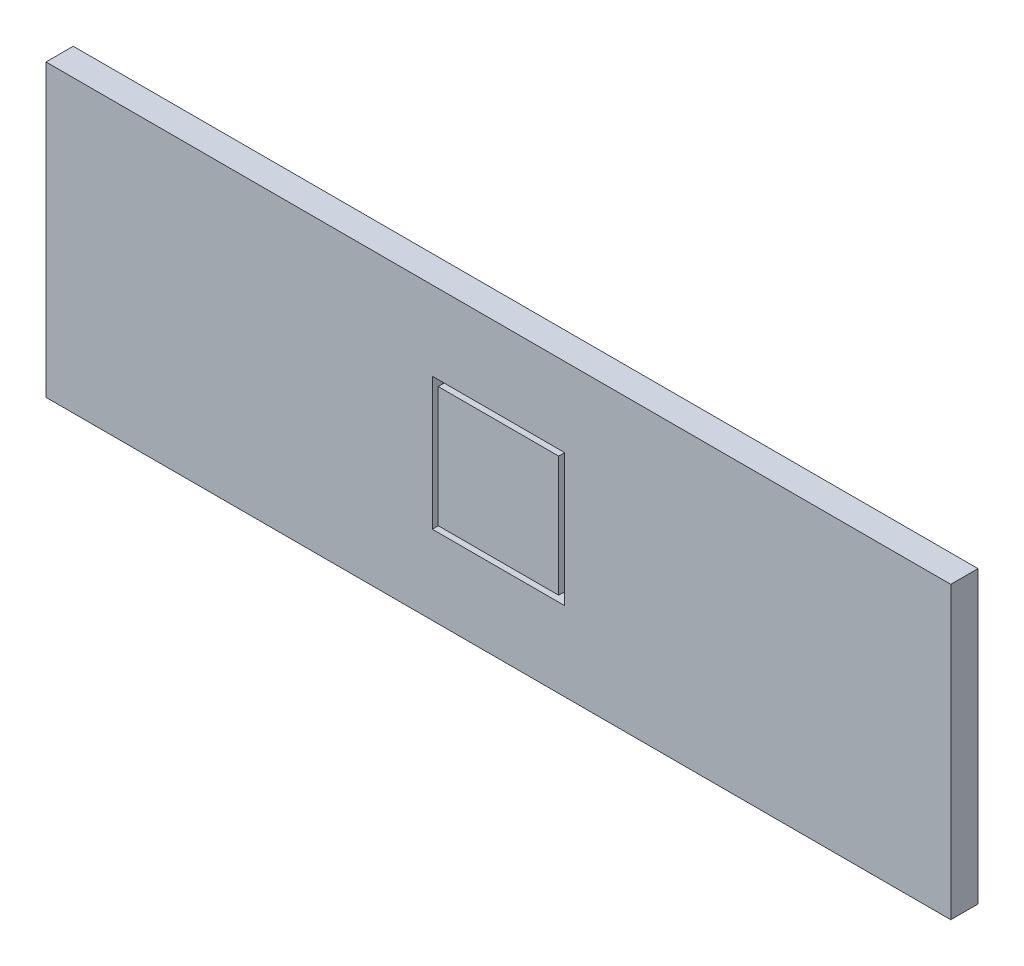
from build123d import *

# Parameters (mm, degrees)
SKETCH1_W           = 598
SKETCH1_H           = 192
BOSS_EXTRUDE1_DEPTH = 18
SKETCH2_W           = 87.4
SKETCH2_H           = 87.6
SKETCH2_W_2         = 79.646425984
SKETCH2_H_2         = 79.646425984
CUT_EXTRUDE1_DEPTH  = 7
CUT_EXTRUDE2_DEPTH  = 10.5


with BuildPart() as part:
    # Sketch1 → Boss-Extrude1 (new body)
    with BuildSketch(Plane.XY):
        Rectangle(SKETCH1_W, SKETCH1_H)
    extrude(amount=BOSS_EXTRUDE1_DEPTH)

    # Sketch2 → Cut-Extrude1 (cut)
    with BuildSketch(Plane.XY.offset(18)):
        Rectangle(SKETCH2_W, SKETCH2_H)
        Rectangle(SKETCH2_W_2, SKETCH2_H_2, mode=Mode.SUBTRACT)
    extrude(amount=-CUT_EXTRUDE1_DEPTH, mode=Mode.SUBTRACT)

    # Sketch3 → Cut-Extrude2 (cut)
    with BuildSketch(Plane.XY.offset(11)):
        with BuildLine():
            Line((30, -33.2), (-30, -33.2))
            Line((-30, -33.2), (-30, -5.0989999))
            ThreePointArc((-30, -5.0989999), (-25.197000899, -0.1), (-30, 4.8989999))
            Line((-30, 4.8989999), (-30, 33.8))
            Line((-30, 33.8), (30, 33.8))
            Line((30, 33.8), (30, 4.8989999))
            ThreePointArc((30, 4.8989999), (25.197000899, -0.1), (30, -5.0989999))
            Line((30, -5.0989999), (30, -33.2))
        make_face()
        with BuildLine():
            Line((26.16375103, -28.91618865), (-26.16375103, -28.91618865))
            Line((-26.16375103, -28.91618865), (-26.16375103, -8.093369002))
            ThreePointArc((-26.16375103, -8.093369002), (-21.245378078, -0.1), (-26.16375103, 7.893369002))
            Line((-26.16375103, 7.893369002), (-26.16375103, 29.51618865))
            Line((-26.16375103, 29.51618865), (26.16375103, 29.51618865))
            Line((26.16375103, 29.51618865), (26.16375103, 7.893369002))
            ThreePointArc((26.16375103, 7.893369002), (21.245378078, -0.1), (26.16375103, -8.093369002))
            Line((26.16375103, -8.093369002), (26.16375103, -28.91618865))
        make_face(mode=Mode.SUBTRACT)
    extrude(amount=-CUT_EXTRUDE2_DEPTH, mode=Mode.SUBTRACT)


solid = part.part
